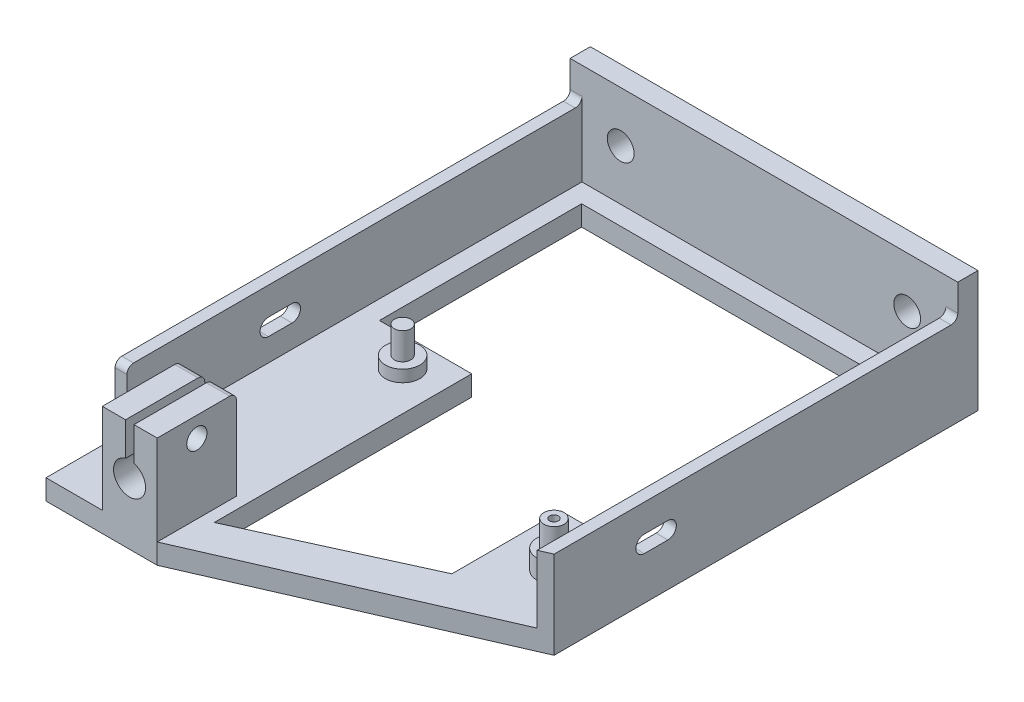
from build123d import *

# Parameters (mm, degrees)
SKETCH1_W                               = 115
SKETCH1_H                               = 170
BACK_WALL_EXTRUDE_DEPTH                 = 6
SKETCH2_W                               = 115
SKETCH2_H                               = 6
BOTTOM_PLATE_EXTRUDE_DEPTH              = 30
SKETCH3_W                               = 3.5
SKETCH3_H                               = 135
SIDE_WALLS_EXTRUDE_DEPTH                = 20
SKETCH4_W                               = 16.3
SKETCH4_H                               = 23.5
DIAL_INDIACTOR_HOLDER_EXTRUDE_DEPTH     = 26.7
SKETCH6_R                               = 3
DIAL_INDICATOR_TIGHTENER_HOLE_CUT_DEPTH = 26.7
DIAL_INDICATOR_HOLDER_CUT_DEPTH         = 30
SKETCH7_R                               = 5.1
ARM_BASE_EXTRUDE_DEPTH                  = 5.7
SKETCH8_R                               = 3
ARM_AXLE_EXTRUDE_DEPTH                  = 7.6
SKETCH9_R                               = 5.1
GUIDE_WHEEL_BASE_EXTRUDE_DEPTH          = 3.5
SKETCH10_R                              = 2.45
GUIDE_WHEEL_AXLE_EXTRUDE_DEPTH          = 8
FILAMENT_SLOT_CUT_DEPTH                 = 116
SKETCH13_R                              = 3.96875
MOUNTING_HOLES_CUT_DEPTH                = 8
FILLET1_R                               = 2
SKETCH15_R                              = 1.3
SCREW_HOLE_CUT_DEPTH                    = 20.3
WEIGHT_REDUCTION_CUT_REACH              = 8
WEIGHT_REDUCTION_CUT_2_DEPTH            = 20


with BuildPart() as part:
    # Sketch1 → Back Wall Extrude (new body)
    with BuildSketch(Plane(origin=(0, 0, 0), x_dir=(1, 0, 0), z_dir=(0, 1, 0))):
        Rectangle(SKETCH1_W, SKETCH1_H)
    extrude(amount=BACK_WALL_EXTRUDE_DEPTH)

    # Sketch2 → Bottom Plate Extrude (add)
    with BuildSketch(Plane(origin=(0, 6, 0), x_dir=(1, 0, 0), z_dir=(0, 1, 0))):
        with Locations((0, 82)):
            Rectangle(SKETCH2_W, SKETCH2_H)
    extrude(amount=BOTTOM_PLATE_EXTRUDE_DEPTH)

    # Sketch3 → Side Walls Extrude (add)
    with BuildSketch(Plane(origin=(0, 6, 0), x_dir=(1, 0, 0), z_dir=(0, 1, 0))):
        with Locations((-55.75, 11.5)):
            Rectangle(SKETCH3_W, SKETCH3_H)
        with Locations((55.75, 11.5)):
            Rectangle(SKETCH3_W, SKETCH3_H)
    extrude(amount=SIDE_WALLS_EXTRUDE_DEPTH)

    # Sketch4 → Dial Indiactor Holder Extrude (add)
    with BuildSketch(Plane(origin=(0, 6, 0), x_dir=(1, 0, 0), z_dir=(0, 1, 0))):
        with Locations((-32.65, -64.75)):
            Rectangle(SKETCH4_W, SKETCH4_H)
    extrude(amount=DIAL_INDIACTOR_HOLDER_EXTRUDE_DEPTH)

    # Sketch6 → Dial Indicator Tightener Hole Cut (cut)
    with BuildSketch(Plane.ZY.offset(40.8)):
        with Locations((64.75, 26.7)):
            Circle(SKETCH6_R)
    extrude(amount=-DIAL_INDICATOR_TIGHTENER_HOLE_CUT_DEPTH, mode=Mode.SUBTRACT)

    # Sketch18 → Dial Indicator Holder Cut (cut)
    with BuildSketch(Plane.XY.offset(76.5)):
        with BuildLine():
            Line((-33.9, 32.7), (-31.4, 32.7))
            Line((-31.4, 32.7), (-31.4, 22.765337686))
            ThreePointArc((-31.4, 22.765337686), (-32.775371215, 13.450428626), (-33.9, 22.798925129))
            Line((-33.9, 22.798925129), (-33.9, 32.7))
        make_face()
    extrude(amount=-DIAL_INDICATOR_HOLDER_CUT_DEPTH, mode=Mode.SUBTRACT)

    # Sketch7 → Arm Base Extrude (add)
    with BuildSketch(Plane(origin=(0, 6, 0), x_dir=(1, 0, 0), z_dir=(0, 1, 0))):
        with Locations((41.6, -24.9)):
            Circle(SKETCH7_R)
    extrude(amount=ARM_BASE_EXTRUDE_DEPTH)

    # Sketch8 → Arm Axle Extrude (add)
    with BuildSketch(Plane(origin=(0, 11.7, 0), x_dir=(1, 0, 0), z_dir=(0, 1, 0))):
        with Locations((41.6, -24.9)):
            Circle(SKETCH8_R)
    extrude(amount=ARM_AXLE_EXTRUDE_DEPTH)

    # Sketch9 → Guide Wheel Base Extrude (add)
    with BuildSketch(Plane(origin=(0, 6, 0), x_dir=(1, 0, 0), z_dir=(0, 1, 0))):
        with Locations((-32.6, 4.4)):
            Circle(SKETCH9_R)
    extrude(amount=GUIDE_WHEEL_BASE_EXTRUDE_DEPTH)

    # Sketch10 → Guide Wheel Axle Extrude (add)
    with BuildSketch(Plane(origin=(0, 9.5, 0), x_dir=(1, 0, 0), z_dir=(0, 1, 0))):
        with Locations((-32.6, 4.4)):
            Circle(SKETCH10_R)
    extrude(amount=GUIDE_WHEEL_AXLE_EXTRUDE_DEPTH)

    # Sketch11 → Filament Slot Cut (cut, through all)
    with BuildSketch(Plane.ZY.offset(57.5)):
        with BuildLine():
            Line((14, 12.765586), (7, 12.765586))
            ThreePointArc((7, 12.765586), (4.5, 15.265586), (7, 17.765586))
            Line((7, 17.765586), (14, 17.765586))
            ThreePointArc((14, 17.765586), (16.5, 15.265586), (14, 12.765586))
        make_face()
    extrude(amount=-FILAMENT_SLOT_CUT_DEPTH, mode=Mode.SUBTRACT)

    # Sketch13 → Mounting Holes Cut (cut)
    with BuildSketch(Plane(origin=(0, 0, -85), x_dir=(-1, 0, 0), z_dir=(0, 0, -1))):
        with Locations((42.5, 21)):
            Circle(SKETCH13_R)
        with Locations((-42.5, 21)):
            Circle(SKETCH13_R)
    extrude(amount=-MOUNTING_HOLES_CUT_DEPTH, mode=Mode.SUBTRACT)

    # Fillet1
    fillet1_edges = [part.edges().sort_by_distance(p)[0] for p in [
        (-55.75, 26, 56),
        (-55.75, 26, -79),
        (55.75, 26, -79),
        (55.75, 26, 56),
        (-27.95, 32.7, 53),
        (-37.35, 32.7, 53),
        (-57.5, 3, 85),
    ]]
    fillet(fillet1_edges, radius=FILLET1_R)

    # Sketch15 → Screw Hole Cut (cut, through all)
    with BuildSketch(Plane(origin=(0, 19.3, 0), x_dir=(1, 0, 0), z_dir=(0, 1, 0))):
        with Locations((41.6, -24.9)):
            Circle(SKETCH15_R)
    extrude(amount=-SCREW_HOLE_CUT_DEPTH, mode=Mode.SUBTRACT)

    # Sketch21 → Weight Reduction Cut (cut, up to next)
    with BuildSketch(Plane(origin=(0, 6, 0), x_dir=(1, 0, 0), z_dir=(0, 1, 0)), mode=Mode.PRIVATE) as weight_reduction_cut_sk1:
        Polygon((-48.44610903, 73.348314607), (48.898876404, 73.348314607), (48.898876404, 13.356637536), (48.898876404, -8.639749456), (27.392426134, -8.639749456), (27.392426134, -40.975447357), (-21.053682896, -63.034891603), (-21.053682896, 13.356637536), (-48.44610903, 13.356637536), align=None)
    weight_reduction_cut_tool1 = extrude(weight_reduction_cut_sk1.sketch, amount=-WEIGHT_REDUCTION_CUT_REACH, mode=Mode.PRIVATE) & part.part
    add(weight_reduction_cut_tool1.solids().sort_by_distance((2.646642, 6, -20.266546))[0], mode=Mode.SUBTRACT)

    # Sketch22 → Weight Reduction Cut 2 (cut, symmetric)
    with BuildSketch(Plane(origin=(0, 6, 0), x_dir=(1, 0, 0), z_dir=(0, 1, 0))):
        Polygon((57.5, -40.74906367), (-24.5, -76.5), (-57.5, -76.5), (-57.5, -85), (57.5, -85), align=None)
    extrude(amount=WEIGHT_REDUCTION_CUT_2_DEPTH, both=True, mode=Mode.SUBTRACT)


solid = part.part
